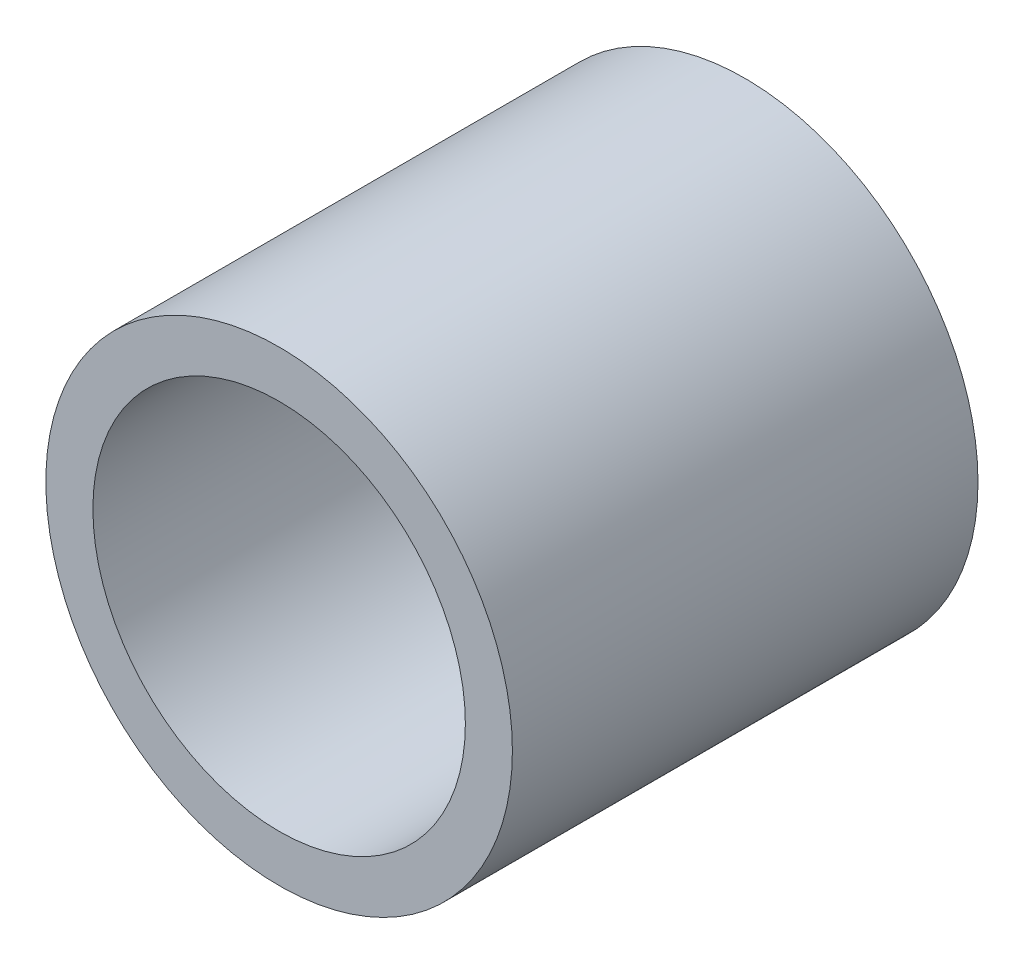
from build123d import *

# Parameters (mm, degrees)
SKETCH1_R           = 7.95401
SKETCH1_R_2         = 6.35
BOSS_EXTRUDE1_DEPTH = 15.875


with BuildPart() as part:
    # Sketch1 → Boss-Extrude1 (new body)
    with BuildSketch(Plane.XY):
        Circle(SKETCH1_R)
        Circle(SKETCH1_R_2, mode=Mode.SUBTRACT)
    extrude(amount=BOSS_EXTRUDE1_DEPTH)


solid = part.part
